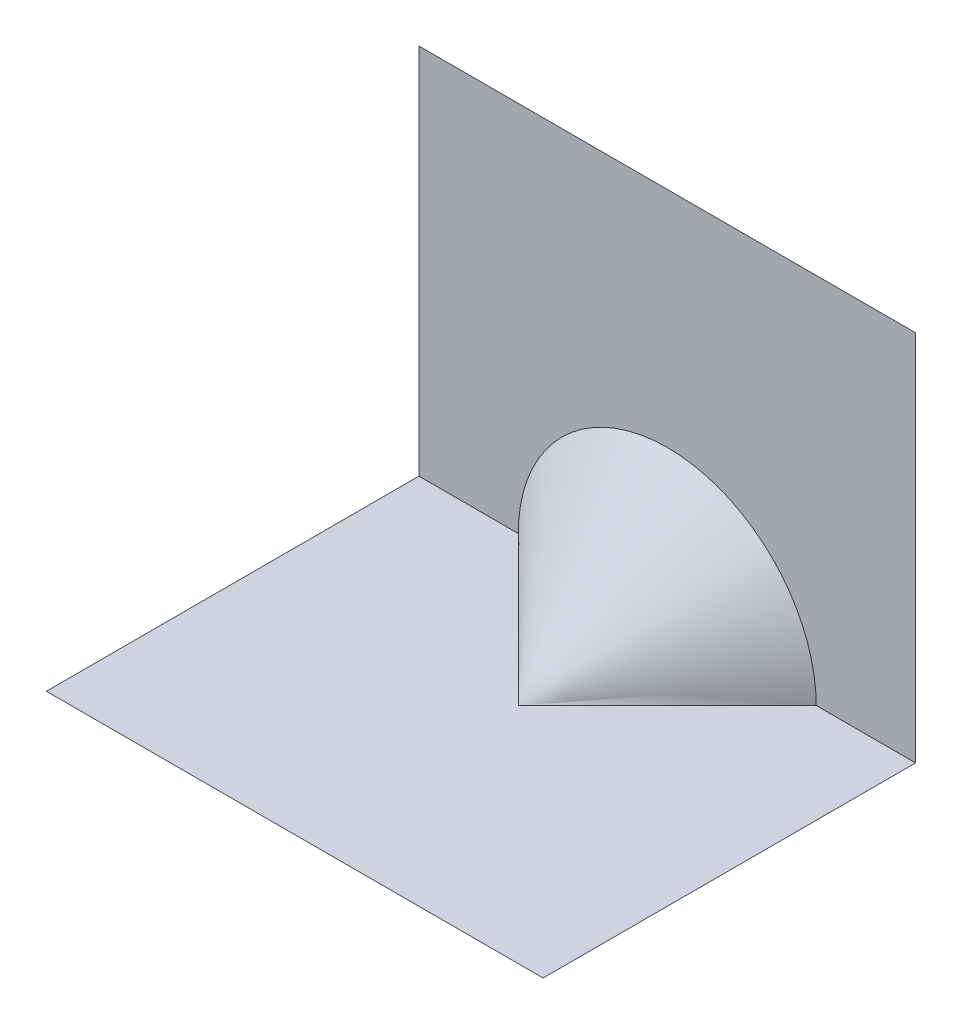
from build123d import *

# Parameters (mm, degrees)
SKETCH1_W      = 200
SKETCH1_H      = 150
EXTRUDE1_DEPTH = 0.0001
SKETCH2_W      = 200
SKETCH2_H      = 150
EXTRUDE2_DEPTH = 0.0001
REVOLVE2_ANGLE = 180


with BuildPart() as part:
    # Sketch1 → Extrude1 (new body)
    with BuildSketch(Plane.XY):
        with Locations((0, 75)):
            Rectangle(SKETCH1_W, SKETCH1_H)
    extrude(amount=-EXTRUDE1_DEPTH)


with BuildPart() as body_2:
    # Sketch2 → Extrude2 (new body)
    with BuildSketch(Plane(origin=(0, 0, 0), x_dir=(1, 0, 0), z_dir=(0, 1, 0))):
        with Locations((0, -75)):
            Rectangle(SKETCH2_W, SKETCH2_H)
    extrude(amount=-EXTRUDE2_DEPTH)


with BuildPart() as body_3:
    # Sketch3 → Revolve2 (revolve)
    with BuildSketch(Plane(origin=(0, 0, 0), x_dir=(-1, 0, 0), z_dir=(0, 1, 0))):
        Polygon((60, 0), (0, 60), (0, 0), align=None)
    revolve(axis=Axis((0, 0, 60), (0, 0, -1)), revolution_arc=REVOLVE2_ANGLE)


solid = Compound([part.part, body_2.part, body_3.part])
